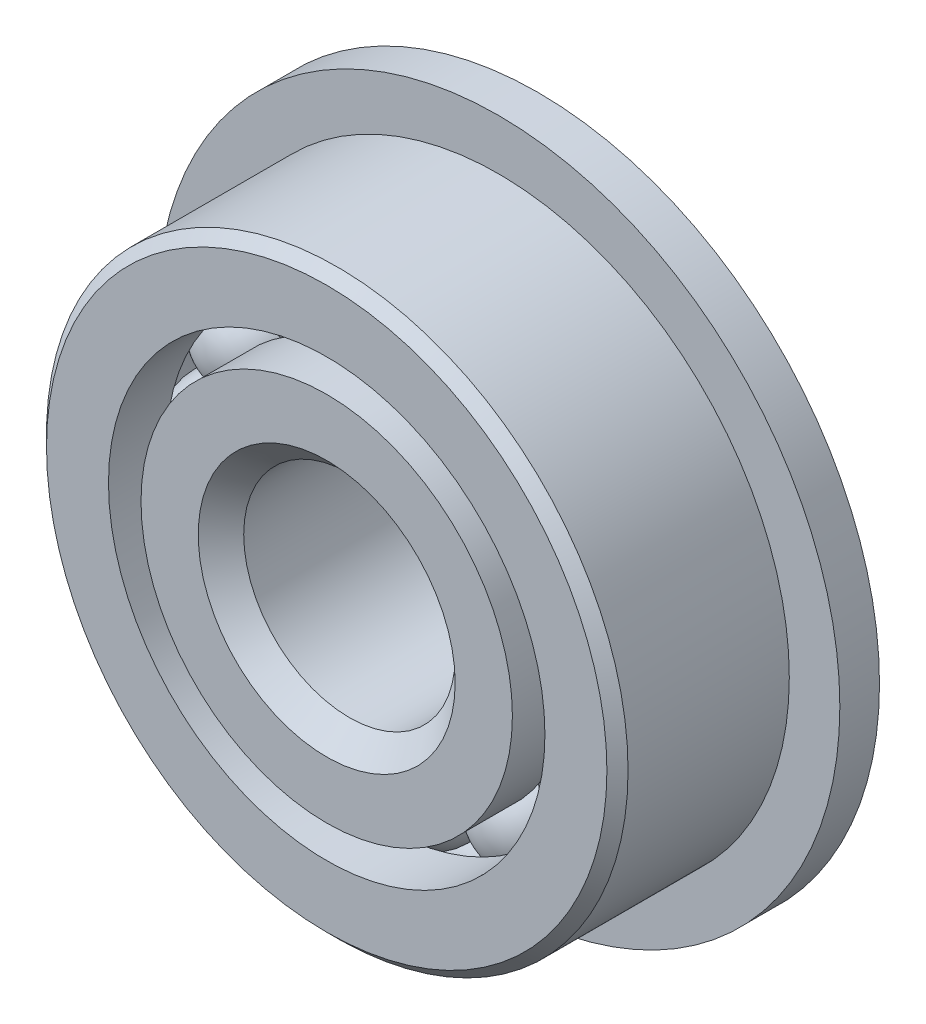
from build123d import *

# Parameters (mm, degrees)
CIRPATTERN1_COUNT = 12
SKETCH5_W         = 1.190625
SKETCH5_H         = 2.765669231


with BuildPart() as part:
    # Sketch1 → Revolve1 (revolve)
    with BuildSketch(Plane(origin=(0, 0, 0), x_dir=(0, 0, -1), z_dir=(1, 0, 0))):
        with BuildLine():
            Line((2.8575, 8.73125), (-2.8575, 8.73125))
            Line((-2.8575, 8.73125), (-3.175, 8.41375))
            Line((-3.175, 8.41375), (-3.175, 6.552711538))
            Line((-3.175, 6.552711538), (-1.443600127, 6.552711538))
            ThreePointArc((-1.443600127, 6.552711538), (0, 7.58825), (1.443600127, 6.552711538))
            Line((1.443600127, 6.552711538), (3.175, 6.552711538))
            Line((3.175, 6.552711538), (3.175, 8.41375))
            Line((3.175, 8.41375), (2.8575, 8.73125))
        make_face()
    revolve(axis=Axis((0, 0, 3.175), (0, 0, -1)))

    # Sketch5 → Revolve5 (revolve)
    with BuildSketch(Plane(origin=(0, 0, 0), x_dir=(0, 0, -1), z_dir=(1, 0, 0))):
        with Locations((2.5796875, 8.866065385)):
            Rectangle(SKETCH5_W, SKETCH5_H)
    revolve(axis=Axis((0, 0, -4.7625), (0, 0, 1)))


with BuildPart() as body_2:
    # Sketch2 → Revolve2 (revolve)
    with BuildSketch(Plane(origin=(0, 0, 0), x_dir=(0, 0, -1), z_dir=(1, 0, 0))):
        with BuildLine():
            Line((-3.175, 5.575788462), (-1.443600127, 5.575788462))
            ThreePointArc((-1.443600127, 5.575788462), (-0.888301924, 4.825906069), (0, 4.54025))
            Line((0, 4.54025), (0, 3.857625))
            Line((0, 3.857625), (-2.315918269, 3.857625))
            Line((-2.315918269, 3.857625), (-3.175, 4.716706731))
            Line((-3.175, 4.716706731), (-3.175, 5.575788462))
        make_face()
    revolve(axis=Axis((0, 0, 3.175), (0, 0, -1)))

    # Sketch3 → Revolve3 (revolve)
    with BuildSketch(Plane(origin=(0, 0, 0), x_dir=(0, 0, -1), z_dir=(1, 0, 0))):
        with BuildLine():
            Line((-3.175, 4.716706731), (-2.315918269, 3.857625))
            Line((-2.315918269, 3.857625), (0, 3.857625))
            Line((0, 3.857625), (0, 4.54025))
            ThreePointArc((0, 4.54025), (0.888301924, 4.825906069), (1.443600127, 5.575788462))
            Line((1.443600127, 5.575788462), (4.7625, 5.575788462))
            Line((4.7625, 5.575788462), (4.7625, 3.4925))
            Line((4.7625, 3.4925), (4.445, 3.175))
            Line((4.445, 3.175), (-2.492375, 3.175))
            Line((-2.492375, 3.175), (-3.175, 3.857625))
            Line((-3.175, 3.857625), (-3.175, 4.716706731))
        make_face()
    revolve(axis=Axis((0, 0, 3.175), (0, 0, -1)))


with BuildPart() as body_3:
    # Sketch4 → Revolve4 (revolve)
    with BuildSketch(Plane(origin=(0, 0, 0), x_dir=(0, 0, -1), z_dir=(1, 0, 0))):
        with BuildLine():
            Line((-1.524, 6.06425), (1.524, 6.06425))
            ThreePointArc((1.524, 6.06425), (0, 7.58825), (-1.524, 6.06425))
        make_face()
    revolve(axis=Axis((0, 6.06425, 1.524), (0, 0, -1)))


with BuildPart() as cirpattern1_1:
    # CirPattern1: pattern copy
    add(body_3.part.rotate(Axis((0, 0, -3.175), (0, 0, 1)), 1 * 360 / CIRPATTERN1_COUNT))


with BuildPart() as cirpattern1_2:
    # CirPattern1: pattern copy
    add(body_3.part.rotate(Axis((0, 0, -3.175), (0, 0, 1)), 2 * 360 / CIRPATTERN1_COUNT))


with BuildPart() as cirpattern1_3:
    # CirPattern1: pattern copy
    add(body_3.part.rotate(Axis((0, 0, -3.175), (0, 0, 1)), 3 * 360 / CIRPATTERN1_COUNT))


with BuildPart() as cirpattern1_4:
    # CirPattern1: pattern copy
    add(body_3.part.rotate(Axis((0, 0, -3.175), (0, 0, 1)), 4 * 360 / CIRPATTERN1_COUNT))


with BuildPart() as cirpattern1_5:
    # CirPattern1: pattern copy
    add(body_3.part.rotate(Axis((0, 0, -3.175), (0, 0, 1)), 5 * 360 / CIRPATTERN1_COUNT))


with BuildPart() as cirpattern1_6:
    # CirPattern1: pattern copy
    add(body_3.part.rotate(Axis((0, 0, -3.175), (0, 0, 1)), 6 * 360 / CIRPATTERN1_COUNT))


with BuildPart() as cirpattern1_7:
    # CirPattern1: pattern copy
    add(body_3.part.rotate(Axis((0, 0, -3.175), (0, 0, 1)), 7 * 360 / CIRPATTERN1_COUNT))


with BuildPart() as cirpattern1_8:
    # CirPattern1: pattern copy
    add(body_3.part.rotate(Axis((0, 0, -3.175), (0, 0, 1)), 8 * 360 / CIRPATTERN1_COUNT))


with BuildPart() as cirpattern1_9:
    # CirPattern1: pattern copy
    add(body_3.part.rotate(Axis((0, 0, -3.175), (0, 0, 1)), 9 * 360 / CIRPATTERN1_COUNT))


with BuildPart() as cirpattern1_10:
    # CirPattern1: pattern copy
    add(body_3.part.rotate(Axis((0, 0, -3.175), (0, 0, 1)), 10 * 360 / CIRPATTERN1_COUNT))


with BuildPart() as cirpattern1_11:
    # CirPattern1: pattern copy
    add(body_3.part.rotate(Axis((0, 0, -3.175), (0, 0, 1)), 11 * 360 / CIRPATTERN1_COUNT))


solid = Compound([part.part, body_2.part, body_3.part, cirpattern1_1.part, cirpattern1_2.part, cirpattern1_3.part, cirpattern1_4.part, cirpattern1_5.part, cirpattern1_6.part, cirpattern1_7.part, cirpattern1_8.part, cirpattern1_9.part, cirpattern1_10.part, cirpattern1_11.part])
